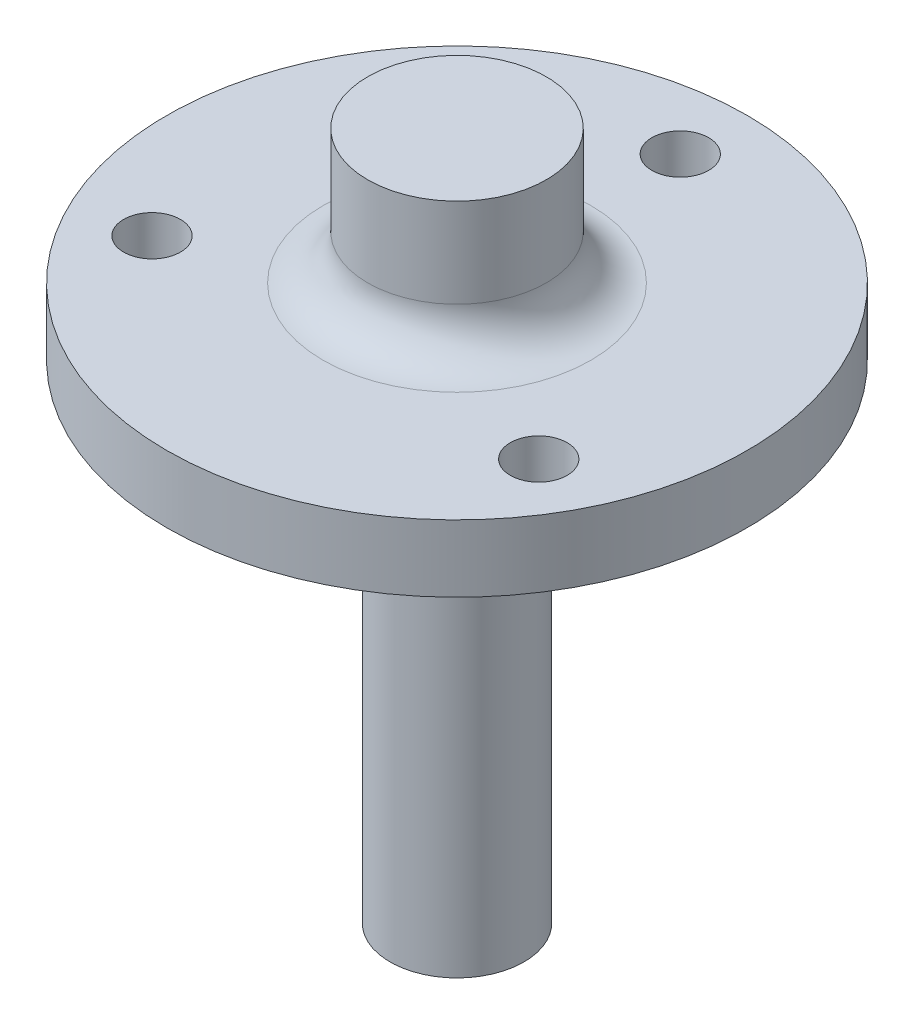
from build123d import *

# Parameters (mm, degrees)
SKETCH1_R                         = 20.6375
BOSS_EXTRUDE1_DEPTH               = 4.7625
SKETCH2_R                         = 8.73125
BOSS_EXTRUDE2_DEPTH               = 6.096
SKETCH5_R                         = 4.7625
BOSS_EXTRUDE3_DEPTH               = 28.575
F_1_4_20_TAPPED_HOLE2_D           = 5.1054
F_1_4_20_TAPPED_HOLE2_DEPTH       = 29.21
F_1_4_20_TAPPED_HOLE2_CBORE_D     = 6.35
F_1_4_20_TAPPED_HOLE2_CBORE_DEPTH = 25.4
F_1_4_20_TAPPED_HOLE2_TIP         = 1.533816902
F_10_32_TAPPED_HOLE1_D            = 4.0386
SKETCH11_R                        = 6.35
BOSS_EXTRUDE4_DEPTH               = 9.525
FILLET1_R                         = 3.175


with BuildPart() as part:
    # Sketch1 → Boss-Extrude1 (new body)
    with BuildSketch(Plane(origin=(0, 0, 0), x_dir=(1, 0, 0), z_dir=(0, 1, 0))):
        Circle(SKETCH1_R)
    extrude(amount=BOSS_EXTRUDE1_DEPTH)

    # Sketch2 → Boss-Extrude2 (add)
    with BuildSketch(Plane.XZ):
        Circle(SKETCH2_R)
    extrude(amount=BOSS_EXTRUDE2_DEPTH)

    # Sketch5 → Boss-Extrude3 (add)
    with BuildSketch(Plane.XZ.offset(6.096)):
        Circle(SKETCH5_R)
    extrude(amount=BOSS_EXTRUDE3_DEPTH)

    # 1/4-20 Tapped Hole2
    with Locations(Plane(origin=(0, -34.671, 0), x_dir=(-1, 0, 0), z_dir=(0, -1, 0))):
        with Locations((0, 0)):
            CounterBoreHole(F_1_4_20_TAPPED_HOLE2_D / 2, F_1_4_20_TAPPED_HOLE2_CBORE_D / 2, F_1_4_20_TAPPED_HOLE2_CBORE_DEPTH, depth=F_1_4_20_TAPPED_HOLE2_DEPTH)
            with Locations((0, 0, -(F_1_4_20_TAPPED_HOLE2_DEPTH + F_1_4_20_TAPPED_HOLE2_TIP / 2))):  # 118° drill point
                Cone(0, F_1_4_20_TAPPED_HOLE2_D / 2, F_1_4_20_TAPPED_HOLE2_TIP, mode=Mode.SUBTRACT)

    # #10-32 Tapped Hole1 (through all)
    with Locations(Plane(origin=(0, 0, 0), x_dir=(-1, 0, 0), z_dir=(0, -1, 0))):
        with Locations((-13.748153285, -7.9375), (0, 15.875), (13.748153285, -7.9375)):
            Hole(F_10_32_TAPPED_HOLE1_D / 2)

    # Sketch11 → Boss-Extrude4 (add)
    with BuildSketch(Plane(origin=(0, 4.7625, 0), x_dir=(1, 0, 0), z_dir=(0, 1, 0))):
        Circle(SKETCH11_R)
    extrude(amount=BOSS_EXTRUDE4_DEPTH)

    # Fillet1
    fillet1_edges = [part.edges().sort_by_distance(p)[0] for p in [
        (-6.35, 4.7625, 0),
    ]]
    fillet(fillet1_edges, radius=FILLET1_R)


solid = part.part
